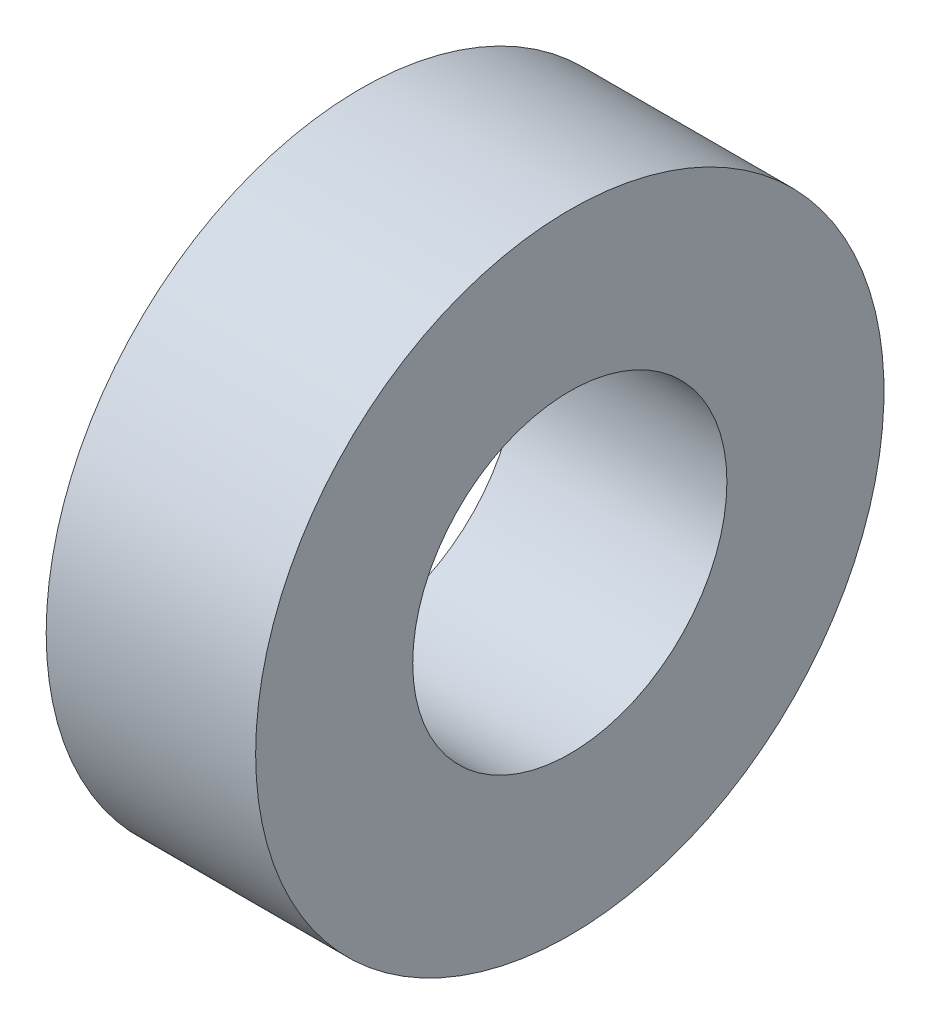
from build123d import *

# Parameters (mm, degrees)
SKETCH3_W = 2
SKETCH3_H = 1.5


with BuildPart() as part:
    # Sketch3 → Revolve1 (revolve)
    with BuildSketch(Plane.XY):
        with Locations((1, 2.25)):
            Rectangle(SKETCH3_W, SKETCH3_H)
    revolve(axis=Axis((0, 0, 0), (1, 0, 0)))


solid = part.part
